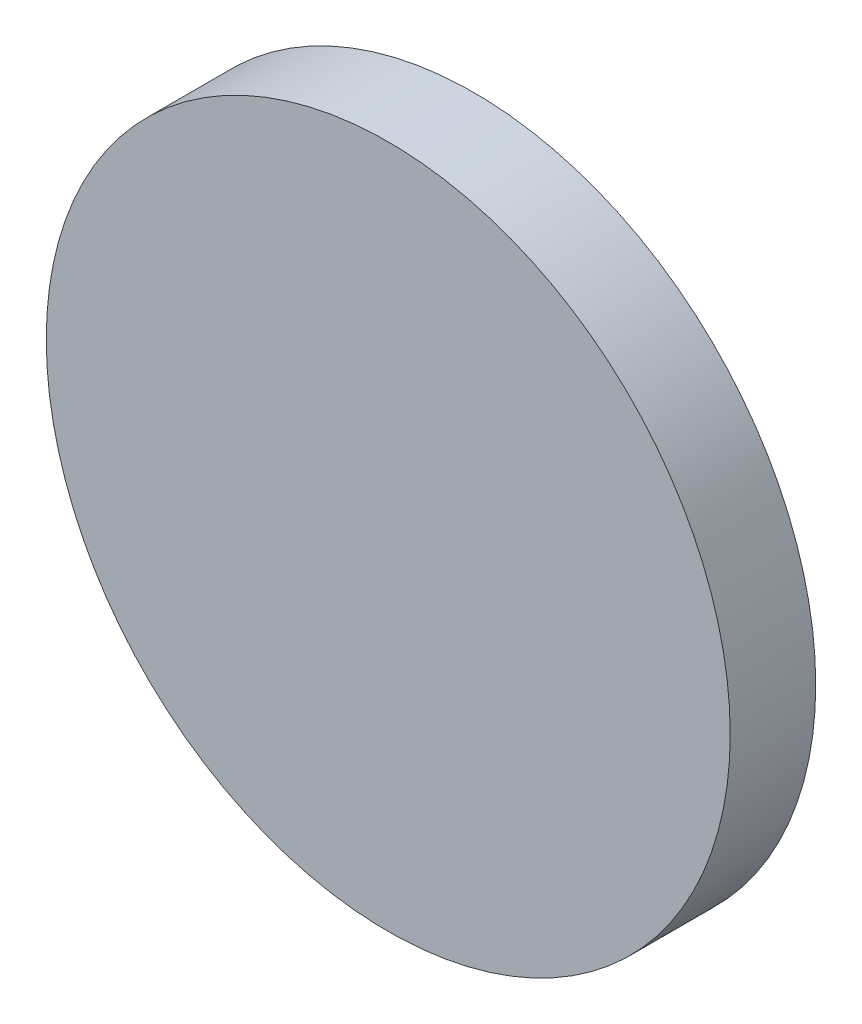
from build123d import *

# Parameters (mm, degrees)
SKIZZE1_R                       = 40
AUFSATZ_LINEAR_AUSTRAGEN1_DEPTH = 10


with BuildPart() as part:
    # Skizze1 → Aufsatz-Linear austragen1 (new body)
    with BuildSketch(Plane.XY):
        Circle(SKIZZE1_R)
    extrude(amount=AUFSATZ_LINEAR_AUSTRAGEN1_DEPTH)


solid = part.part
